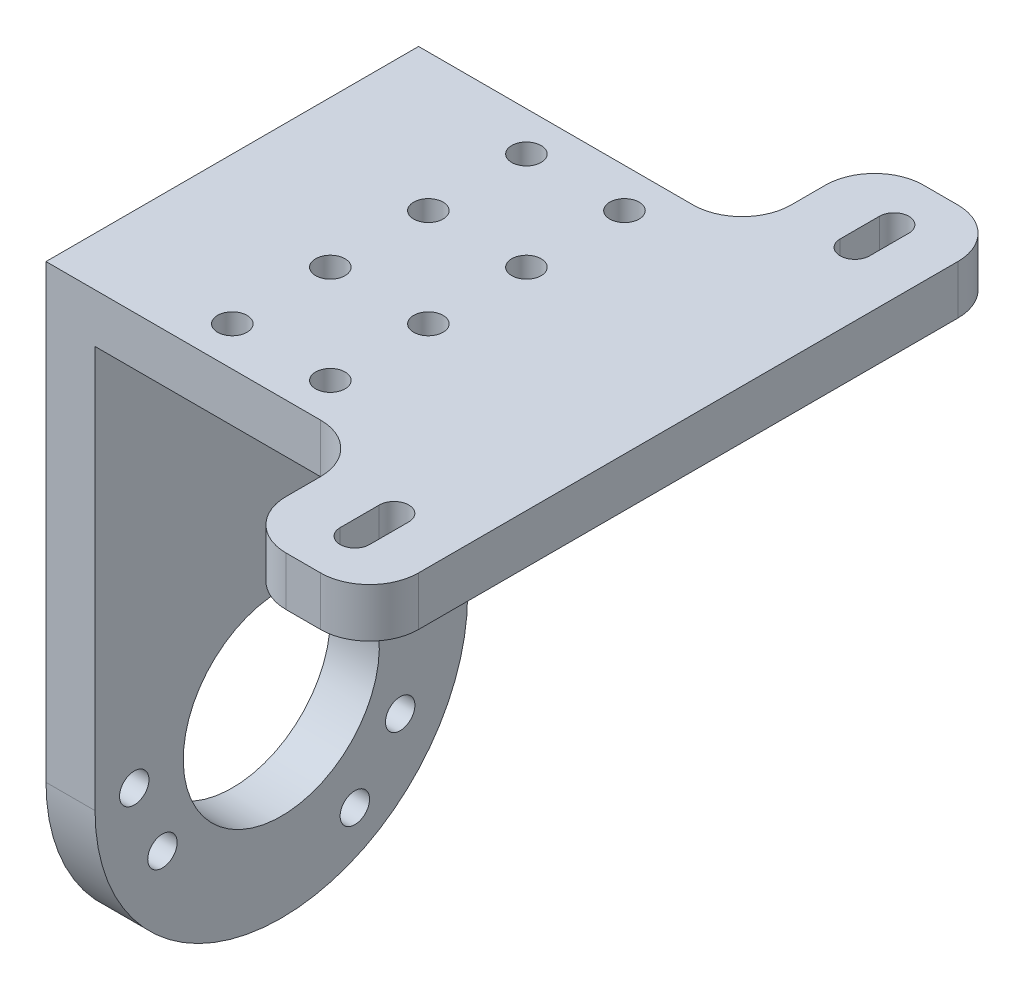
from build123d import *

# Parameters (mm, degrees)
EXTRUDE_1_DEPTH          = 32.5
EXTRUDE_1_DEPTH_BACK     = 32.5
SKETCH_2_R               = 10
CUT_EXTRUDE_1_DEPTH      = 19
SKETCH_3_R               = 1.5
CUT_EXTRUDE_2_DEPTH      = 70.960703255
SKETCH_4_R               = 1.5
CUT_EXTRUDE_3_DEPTH      = 87.275720803
CUT_EXTRUDE_4_DEPTH      = 74.037661518
CUT_EXTRUDE_4_DEPTH_BACK = 74.037661518
SKETCH_6_W               = 33
SKETCH_6_H               = 13.5
CUT_EXTRUDE_5_DEPTH      = 10
FILLET_3_R               = 5


with BuildPart() as part:
    # Эскиз1 → Бобышка-Вытянуть1 (new, two sides: drawn at the far end of the back side and taken through both)
    with BuildSketch(Plane.XY.offset(-EXTRUDE_1_DEPTH_BACK)):
        Polygon((0, 46), (0, -19), (5, -19), (5, 41), (46.5, 41), (46.5, 46), align=None)
    extrude(amount=EXTRUDE_1_DEPTH + EXTRUDE_1_DEPTH_BACK)

    # Эскиз2 → Вырез-Вытянуть1 (cut)
    with BuildSketch(Plane(origin=(5, 0, 0), x_dir=(0, 0, -1), z_dir=(1, 0, 0))):
        Circle(SKETCH_2_R)
    extrude(amount=-CUT_EXTRUDE_1_DEPTH, mode=Mode.SUBTRACT)

    # Эскиз3 → Вырез-Вытянуть2 (cut, through all)
    with BuildSketch(Plane(origin=(5, 0, 0), x_dir=(0, 0, -1), z_dir=(1, 0, 0))):
        with Locations((0, 14)):
            Circle(SKETCH_3_R)
        with Locations((7.5, 12.990381057)):
            Circle(SKETCH_3_R)
        with Locations((12.124355653, -7)):
            Circle(SKETCH_3_R)
        with Locations((7.5, -12.990381057)):
            Circle(SKETCH_3_R)
        with Locations((-12.124355653, -7)):
            Circle(SKETCH_3_R)
        with Locations((-15, 0)):
            Circle(SKETCH_3_R)
    extrude(amount=-CUT_EXTRUDE_2_DEPTH, mode=Mode.SUBTRACT)

    # Эскиз4 → Вырез-Вытянуть3 (cut, through all)
    with BuildSketch(Plane(origin=(0, 46, 0), x_dir=(1, 0, 0), z_dir=(0, 1, 0))):
        with Locations((15, 15)):
            Circle(SKETCH_4_R)
        with Locations((15, 5)):
            Circle(SKETCH_4_R)
        with Locations((25, 5)):
            Circle(SKETCH_4_R)
        with Locations((25, 15)):
            Circle(SKETCH_4_R)
        with Locations((25, -15)):
            Circle(SKETCH_4_R)
        with Locations((25, -5)):
            Circle(SKETCH_4_R)
        with Locations((15, -5)):
            Circle(SKETCH_4_R)
        with Locations((15, -15)):
            Circle(SKETCH_4_R)
        with BuildLine():
            Line((38.5, 27.5), (38.5, 23.5))
            ThreePointArc((38.5, 23.5), (40, 22), (41.5, 23.5))
            Line((41.5, 23.5), (41.5, 27.5))
            ThreePointArc((41.5, 27.5), (40, 29), (38.5, 27.5))
        make_face()
        with BuildLine():
            Line((38.5, -23.511442769), (38.5, -27.516419302))
            ThreePointArc((38.5, -27.516419302), (40.008164842, -29.000022466), (41.5, -27.5))
            Line((41.5, -27.5), (41.5, -23.488557231))
            ThreePointArc((41.5, -23.488557231), (39.988557231, -22), (38.5, -23.511442769))
        make_face()
    extrude(amount=-CUT_EXTRUDE_3_DEPTH, mode=Mode.SUBTRACT)

    # Эскиз5 → Вырез-Вытянуть4 (cut, two sides: drawn at the far end of the back side and taken through both)
    with BuildSketch(Plane.ZY.offset(-CUT_EXTRUDE_4_DEPTH_BACK)):
        with BuildLine():
            Line((-19, 0), (-19, 40))
            Line((-19, 40), (-39.097198646, 40))
            Line((-39.097198646, 40), (-39.097198646, -21.281436411))
            Line((-39.097198646, -21.281436411), (42.016942769, -21.281436411))
            Line((42.016942769, -21.281436411), (42.016942769, 40))
            Line((42.016942769, 40), (19, 40))
            Line((19, 40), (19, 0))
            ThreePointArc((19, 0), (0, -19), (-19, 0))
        make_face()
    extrude(amount=CUT_EXTRUDE_4_DEPTH + CUT_EXTRUDE_4_DEPTH_BACK, mode=Mode.SUBTRACT)

    # Эскиз6 → Вырез-Вытянуть5 (cut)
    with BuildSketch(Plane(origin=(0, 46, 0), x_dir=(1, 0, 0), z_dir=(0, 1, 0))):
        with Locations((16.5, 25.75)):
            Rectangle(SKETCH_6_W, SKETCH_6_H)
        with Locations((16.5, -25.75)):
            Rectangle(SKETCH_6_W, SKETCH_6_H)
    extrude(amount=-CUT_EXTRUDE_5_DEPTH, mode=Mode.SUBTRACT)

    # Скругление3
    fillet_3_edges = [part.edges().sort_by_distance(p)[0] for p in [
        (46.5, 43.5, -32.5),
        (33, 43.5, -32.5),
        (33, 43.5, -19),
        (46.5, 43.5, 32.5),
        (33, 43.5, 32.5),
        (33, 43.5, 19),
    ]]
    fillet(fillet_3_edges, radius=FILLET_3_R)


solid = part.part
